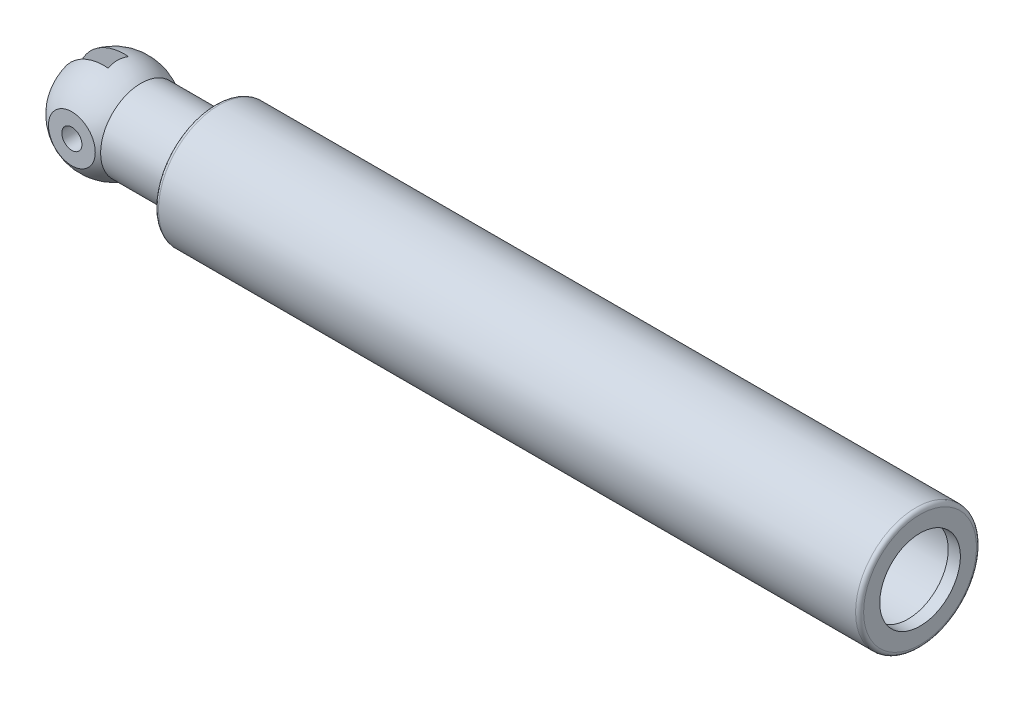
from build123d import *

# Parameters (mm, degrees)
SKETCH6_OUTSIDE_W       = 75.24
SKETCH6_OUTSIDE_H       = 75.24
SKETCH6_OUTSIDE_W_2     = 21
SKETCH6_OUTSIDE_H_2     = 30
CUT_EXTRUDE3_DEPTH      = 40
SKETCH4_W               = 17.5
SKETCH4_H               = 5
FILLET1_R               = 1
SKETCH8_R               = 2.5
CUT_EXTRUDE4_DEPTH      = 5.5
CUT_EXTRUDE4_DEPTH_BACK = 26.5


with BuildPart() as part:
    # Sketch1 → Revolve1 (revolve)
    with BuildSketch(Plane.XY):
        with BuildLine():
            Line((172, 10), (175, 10))
            Line((175, 10), (175, 15))
            Line((175, 15), (0, 15))
            Line((0, 15), (0, 10))
            Line((0, 10), (-18.366750419, 10))
            ThreePointArc((-18.366750419, 10), (-30.674548662, 10.573528147), (-37, 0))
            Line((-37, 0), (0, 0))
            Line((0, 0), (3, 0))
            Line((3, 0), (3, 12))
            Line((3, 12), (172, 12))
            Line((172, 12), (172, 10))
        make_face()
    revolve(axis=Axis((0, 0, 0), (1, 0, 0)))

    # Sketch6 outside → Cut-Extrude3 (cut)
    with BuildSketch(Plane.ZY):
        Rectangle(SKETCH6_OUTSIDE_W, SKETCH6_OUTSIDE_H)
        Rectangle(SKETCH6_OUTSIDE_W_2, SKETCH6_OUTSIDE_H_2, mode=Mode.SUBTRACT)
    extrude(amount=CUT_EXTRUDE3_DEPTH, mode=Mode.SUBTRACT)

    # Sketch4 → Cut-Revolve1 (revolve, cut)
    with BuildSketch(Plane(origin=(0, 0, 0), x_dir=(1, 0, 0), z_dir=(0, 1, 0))):
        with Locations((-28.25, 0)):
            Rectangle(SKETCH4_W, SKETCH4_H)
    revolve(axis=Axis((-37, 0, -2.5), (0, 0, 1)), mode=Mode.SUBTRACT)

    # Fillet1
    fillet1_edges = [part.edges().sort_by_distance(p)[0] for p in [
        (175, -15, 0),
        (0, -15, 0),
        (0, -10, 0),
        (0, -15, 0),
    ]]
    fillet(fillet1_edges, radius=FILLET1_R)

    # Sketch8 → Cut-Extrude4 (cut, two sides)
    with BuildSketch(Plane.XY.offset(10.5)) as cut_extrude4_sk:
        with Locations((-25, 0)):
            Circle(SKETCH8_R)
    extrude(amount=CUT_EXTRUDE4_DEPTH, mode=Mode.SUBTRACT)
    extrude(cut_extrude4_sk.sketch, amount=-CUT_EXTRUDE4_DEPTH_BACK, mode=Mode.SUBTRACT)


solid = part.part
